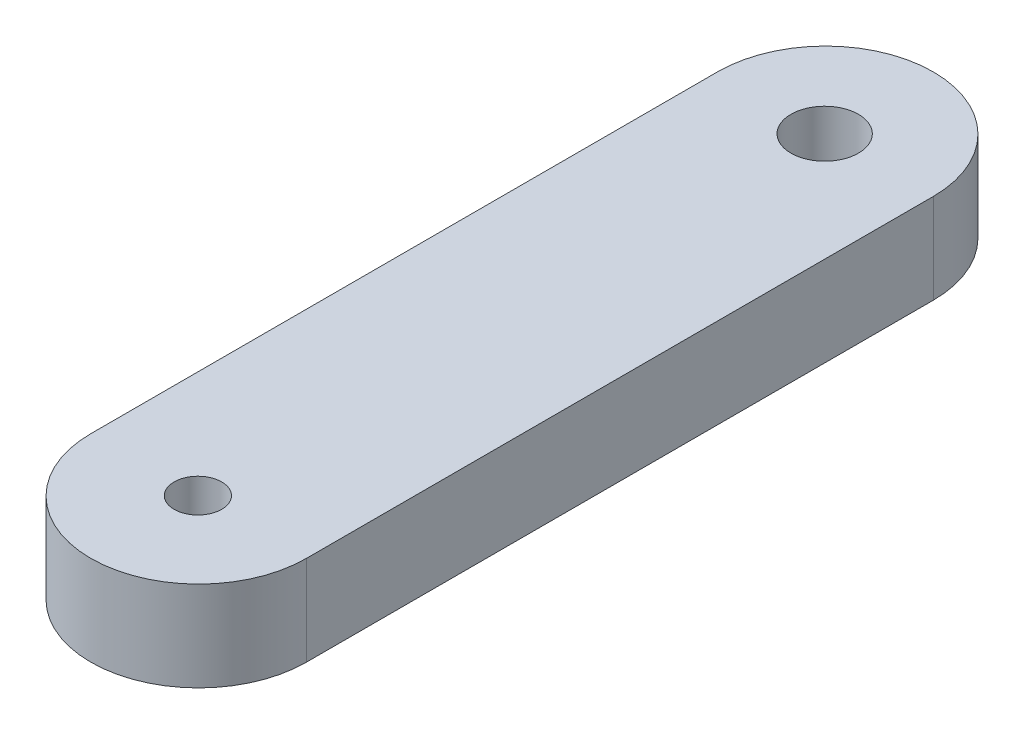
from build123d import *

# Parameters (mm, degrees)
SKETCH1_R           = 1.190625
SKETCH1_R_2         = 0.840105
BOSS_EXTRUDE1_DEPTH = 3.175


with BuildPart() as part:
    # Sketch1 → Boss-Extrude1 (new body)
    with BuildSketch(Plane(origin=(0, 0, 0), x_dir=(1, 0, 0), z_dir=(0, 1, 0))):
        with BuildLine():
            Line((-3.78493816, 0), (-3.78493816, 22.1335092))
            ThreePointArc((-3.78493816, 22.1335092), (0.02506184, 25.9435092), (3.83506184, 22.1335092))
            Line((3.83506184, 22.1335092), (3.83506184, 0))
            ThreePointArc((3.83506184, 0), (0.02506184, -3.81), (-3.78493816, 0))
        make_face()
        with Locations((0, 22.1335092)):
            Circle(SKETCH1_R, mode=Mode.SUBTRACT)
        Circle(SKETCH1_R_2, mode=Mode.SUBTRACT)
    extrude(amount=BOSS_EXTRUDE1_DEPTH)


solid = part.part
